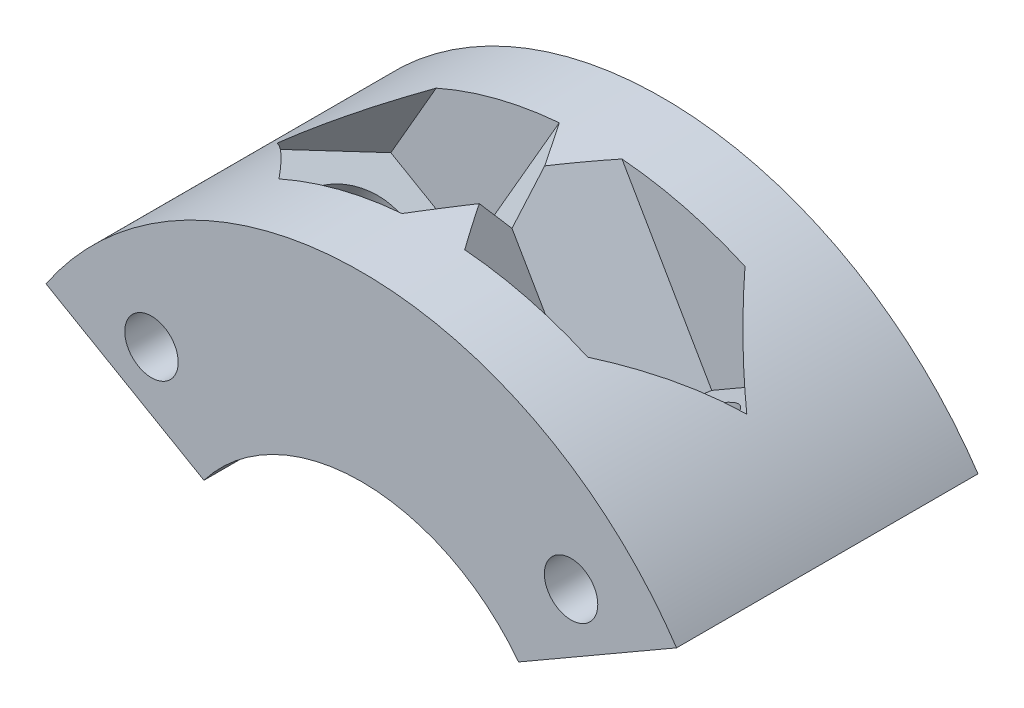
from build123d import *

# Parameters (mm, degrees)
SKETCH1_R           = 2.25
BOSS_EXTRUDE1_DEPTH = 12.7
SKETCH3_R           = 4.35
CUT_EXTRUDE1_DEPTH  = 43.816935902
CUT_EXTRUDE2_START  = 12.7
SKETCH1_3_R         = 2.25
CUT_EXTRUDE2_DEPTH  = 8
CUT_EXTRUDE4_START  = -12.7
SKETCH1_5_R         = 2.25
CUT_EXTRUDE4_DEPTH  = 8
CUT_EXTRUDE3_START  = -9
SKETCH3_3_R         = 4.35
CUT_EXTRUDE3_DEPTH  = 34.816936066


with BuildPart() as part:
    # Sketch1 → Boss-Extrude1 (new, symmetric)
    with BuildSketch(Plane.XY):
        with BuildLine():
            ThreePointArc((-26.566778815, 17.838336901), (0, 32), (26.566778815, 17.838336901))
            Line((26.566778815, 17.838336901), (13.258035703, 10.154530482))
            ThreePointArc((13.258035703, 10.154530482), (0, 16.7), (-13.258035703, 10.154530482))
            Line((-13.258035703, 10.154530482), (-26.566778815, 17.838336901))
        make_face()
        with Locations((17.67766953, 17.67766953)):
            Circle(SKETCH1_R, mode=Mode.SUBTRACT)
        with Locations((-17.67766953, 17.67766953)):
            Circle(SKETCH1_R, mode=Mode.SUBTRACT)
        with Locations((-17.67766953, 17.67766953)):
            Circle(SKETCH1_R)
        with Locations((17.67766953, 17.67766953)):
            Circle(SKETCH1_R)
    extrude(amount=BOSS_EXTRUDE1_DEPTH, both=True)

    # Sketch3 → Cut-Extrude1 (cut, symmetric)
    with BuildSketch(Plane(origin=(-1.082531755, 1.875, 0), x_dir=(0.8660254037844398, 0.4999999999999983, 0), z_dir=(0.4999999999999983, -0.8660254037844398, 0))):
        with Locations((22.059060964, 0)):
            Circle(SKETCH3_R)
    cut_extrude1 = extrude(amount=CUT_EXTRUDE1_DEPTH, both=True, mode=Mode.SUBTRACT)

    # Sketch1_3 → Cut-Extrude2 (cut)
    with BuildSketch(Plane.XY.offset(CUT_EXTRUDE2_START)):
        with Locations((17.67766953, 17.67766953)):
            Circle(SKETCH1_3_R)
    cut_extrude2 = extrude(amount=-CUT_EXTRUDE2_DEPTH, mode=Mode.SUBTRACT)

    # Sketch1_5 → Cut-Extrude4 (cut)
    with BuildSketch(Plane.XY.offset(CUT_EXTRUDE4_START)):
        with Locations((17.67766953, 17.67766953)):
            Circle(SKETCH1_5_R)
    cut_extrude4 = extrude(amount=CUT_EXTRUDE4_DEPTH, mode=Mode.SUBTRACT)

    # Sketch3_3 → Cut-Extrude3 (cut, through all)
    with BuildSketch(Plane(origin=(-1.082531755, 1.875, 0), x_dir=(0.8660254037844398, 0.4999999999999983, 0), z_dir=(0.4999999999999983, -0.8660254037844398, 0)).offset(CUT_EXTRUDE3_START)):
        Polygon((18.23411543, -6.625), (25.884006497, -6.625), (29.70895203, 0), (25.884006497, 6.625), (18.23411543, 6.625), (14.409169897, 0), align=None)
        with Locations((22.059060964, 0)):
            Circle(SKETCH3_3_R, mode=Mode.SUBTRACT)
    cut_extrude3 = extrude(amount=-CUT_EXTRUDE3_DEPTH, mode=Mode.SUBTRACT)

    # Mirror1: Cut-Extrude1, Cut-Extrude2, Cut-Extrude4, Cut-Extrude3 across plane
    add(cut_extrude1.mirror(Plane(origin=(0, 0, 0), x_dir=(0, 0, 1), z_dir=(1, 0, 0))), mode=Mode.SUBTRACT)
    add(cut_extrude2.mirror(Plane(origin=(0, 0, 0), x_dir=(0, 0, 1), z_dir=(1, 0, 0))), mode=Mode.SUBTRACT)
    add(cut_extrude4.mirror(Plane(origin=(0, 0, 0), x_dir=(0, 0, 1), z_dir=(1, 0, 0))), mode=Mode.SUBTRACT)
    add(cut_extrude3.mirror(Plane(origin=(0, 0, 0), x_dir=(0, 0, 1), z_dir=(1, 0, 0))), mode=Mode.SUBTRACT)


solid = part.part
